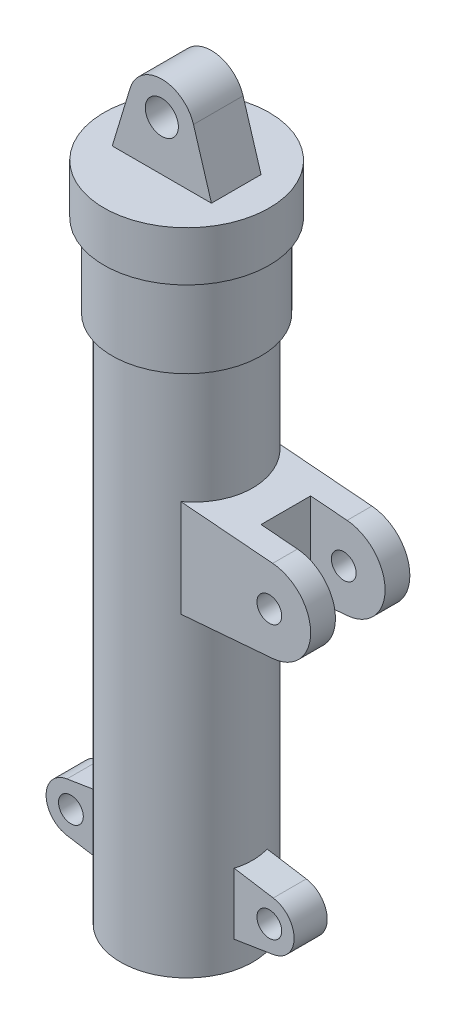
from build123d import *

# Parameters (mm, degrees)
SKETCH2_R           = 10
BOSS_EXTRUDE1_DEPTH = 15
SKETCH3_R           = 7.5
BOSS_EXTRUDE2_DEPTH = 10
SKETCH4_R           = 7.5
BOSS_EXTRUDE3_DEPTH = 30
SKETCH5_W           = 70
SKETCH5_H           = 80
CUT_EXTRUDE1_DEPTH  = 15
SKETCH6_W           = 35
SKETCH6_H           = 315


with BuildPart() as part:
    # Sketch1 → Revolve1 (revolve)
    with BuildSketch(Plane.XY):
        Polygon((0, 400), (50, 400), (50, 370), (45, 370), (45, 320), (40, 320), (40, 0), (22.5, 0), (22.5, 5), (35, 5), (35, 385), (0, 385), align=None)
    revolve(axis=Axis((0, -64.336492891, 0), (0, 1, 0)))

    # Sketch2 → Boss-Extrude1 (add, symmetric)
    with BuildSketch(Plane.XY):
        with BuildLine():
            Line((-30, 400), (30, 400))
            Line((30, 400), (19.138857956, 435.805524623))
            ThreePointArc((19.138857956, 435.805524623), (0, 450), (-19.138857956, 435.805524623))
            Line((-19.138857956, 435.805524623), (-30, 400))
        make_face()
        with Locations((0, 430)):
            Circle(SKETCH2_R, mode=Mode.SUBTRACT)
    extrude(amount=BOSS_EXTRUDE1_DEPTH, both=True)

    # Sketch3 → Boss-Extrude2 (add, symmetric)
    with BuildSketch(Plane.XY):
        with BuildLine():
            Line((30, 15), (30, 55))
            Line((30, 55), (62.373967528, 49.810951292))
            ThreePointArc((62.373967528, 49.810951292), (75, 35), (62.373967528, 20.189048708))
            Line((62.373967528, 20.189048708), (30, 15))
        make_face()
        with Locations((60, 35)):
            Circle(SKETCH3_R, mode=Mode.SUBTRACT)
    boss_extrude2 = extrude(amount=BOSS_EXTRUDE2_DEPTH, both=True)

    # Mirror1: Boss-Extrude2 across plane
    add(boss_extrude2.mirror(Plane(origin=(0, 0, 0), x_dir=(0, 0, 1), z_dir=(1, 0, 0))))

    # Sketch4 → Boss-Extrude3 (add, symmetric)
    with BuildSketch(Plane.XY):
        with BuildLine():
            Line((20, 250), (20, 190))
            Line((20, 190), (82.041582998, 195.08350067))
            ThreePointArc((82.041582998, 195.08350067), (105, 220), (82.041582998, 244.91649933))
            Line((82.041582998, 244.91649933), (20, 250))
        make_face()
        with Locations((80, 220)):
            Circle(SKETCH4_R, mode=Mode.SUBTRACT)
    extrude(amount=BOSS_EXTRUDE3_DEPTH, both=True)

    # Sketch5 → Cut-Extrude1 (cut, symmetric)
    with BuildSketch(Plane.XY):
        with Locations((95, 220)):
            Rectangle(SKETCH5_W, SKETCH5_H)
    extrude(amount=CUT_EXTRUDE1_DEPTH, both=True, mode=Mode.SUBTRACT)

    # Sketch6 → Cut-Revolve1 (revolve, cut)
    with BuildSketch(Plane.XY):
        with Locations((17.5, 162.5)):
            Rectangle(SKETCH6_W, SKETCH6_H)
    revolve(axis=Axis((0, 320, 0), (0, -1, 0)), mode=Mode.SUBTRACT)


solid = part.part
